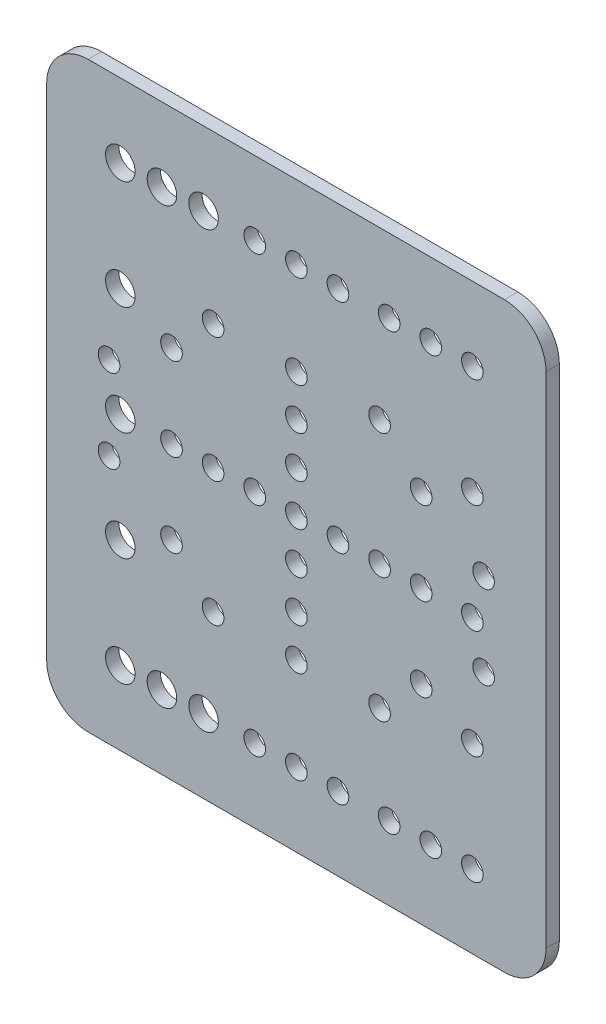
from build123d import *

# Parameters (mm, degrees)
SKETCH1_W           = 120
SKETCH1_H           = 140
SKETCH1_R           = 2.6
SKETCH1_R_2         = 3.55
BOSS_EXTRUDE1_DEPTH = 3.2
FILLET1_R           = 10


with BuildPart() as part:
    # Sketch1 → Boss-Extrude1 (new body)
    with BuildSketch(Plane.XY):
        Rectangle(SKETCH1_W, SKETCH1_H)
        Circle(SKETCH1_R, mode=Mode.SUBTRACT)
        with Locations((10, 0)):
            Circle(SKETCH1_R, mode=Mode.SUBTRACT)
        with Locations((20, 0)):
            Circle(SKETCH1_R, mode=Mode.SUBTRACT)
        with Locations((30, 0)):
            Circle(SKETCH1_R, mode=Mode.SUBTRACT)
        with Locations((-10, 0)):
            Circle(SKETCH1_R, mode=Mode.SUBTRACT)
        with Locations((-20, 0)):
            Circle(SKETCH1_R, mode=Mode.SUBTRACT)
        with Locations((-30, 0)):
            Circle(SKETCH1_R, mode=Mode.SUBTRACT)
        with Locations((0, 10)):
            Circle(SKETCH1_R, mode=Mode.SUBTRACT)
        with Locations((0, 20)):
            Circle(SKETCH1_R, mode=Mode.SUBTRACT)
        with Locations((0, 30)):
            Circle(SKETCH1_R, mode=Mode.SUBTRACT)
        with Locations((0, -10)):
            Circle(SKETCH1_R, mode=Mode.SUBTRACT)
        with Locations((0, -20)):
            Circle(SKETCH1_R, mode=Mode.SUBTRACT)
        with Locations((0, -30)):
            Circle(SKETCH1_R, mode=Mode.SUBTRACT)
        with Locations((42.3, 0)):
            Circle(SKETCH1_R, mode=Mode.SUBTRACT)
        with Locations((-42.3, 0)):
            Circle(SKETCH1_R_2, mode=Mode.SUBTRACT)
        with Locations((-42.3, 26.15)):
            Circle(SKETCH1_R_2, mode=Mode.SUBTRACT)
        with Locations((-42.3, 52.3)):
            Circle(SKETCH1_R_2, mode=Mode.SUBTRACT)
        with Locations((-42.3, -26.15)):
            Circle(SKETCH1_R_2, mode=Mode.SUBTRACT)
        with Locations((-42.3, -52.3)):
            Circle(SKETCH1_R_2, mode=Mode.SUBTRACT)
        with Locations((42.3, 26.15)):
            Circle(SKETCH1_R, mode=Mode.SUBTRACT)
        with Locations((42.3, 52.3)):
            Circle(SKETCH1_R, mode=Mode.SUBTRACT)
        with Locations((42.3, -26.15)):
            Circle(SKETCH1_R, mode=Mode.SUBTRACT)
        with Locations((42.3, -52.3)):
            Circle(SKETCH1_R, mode=Mode.SUBTRACT)
        with Locations((-32.3, 52.3)):
            Circle(SKETCH1_R_2, mode=Mode.SUBTRACT)
        with Locations((-22.3, 52.3)):
            Circle(SKETCH1_R_2, mode=Mode.SUBTRACT)
        with Locations((-32.3, -52.3)):
            Circle(SKETCH1_R_2, mode=Mode.SUBTRACT)
        with Locations((-22.3, -52.3)):
            Circle(SKETCH1_R_2, mode=Mode.SUBTRACT)
        with Locations((32.3, 52.3)):
            Circle(SKETCH1_R, mode=Mode.SUBTRACT)
        with Locations((22.3, 52.3)):
            Circle(SKETCH1_R, mode=Mode.SUBTRACT)
        with Locations((32.3, -52.3)):
            Circle(SKETCH1_R, mode=Mode.SUBTRACT)
        with Locations((22.3, -52.3)):
            Circle(SKETCH1_R, mode=Mode.SUBTRACT)
        with Locations((0, 52.3)):
            Circle(SKETCH1_R, mode=Mode.SUBTRACT)
        with Locations((10, 52.3)):
            Circle(SKETCH1_R, mode=Mode.SUBTRACT)
        with Locations((-10, 52.3)):
            Circle(SKETCH1_R, mode=Mode.SUBTRACT)
        with Locations((-20, 30)):
            Circle(SKETCH1_R, mode=Mode.SUBTRACT)
        with Locations((20, 30)):
            Circle(SKETCH1_R, mode=Mode.SUBTRACT)
        with Locations((-30, 20)):
            Circle(SKETCH1_R, mode=Mode.SUBTRACT)
        with Locations((30, 20)):
            Circle(SKETCH1_R, mode=Mode.SUBTRACT)
        with Locations((-45, 10)):
            Circle(SKETCH1_R, mode=Mode.SUBTRACT)
        with Locations((45, 10)):
            Circle(SKETCH1_R, mode=Mode.SUBTRACT)
        with Locations((45, -10)):
            Circle(SKETCH1_R, mode=Mode.SUBTRACT)
        with Locations((30, -20)):
            Circle(SKETCH1_R, mode=Mode.SUBTRACT)
        with Locations((20, -30)):
            Circle(SKETCH1_R, mode=Mode.SUBTRACT)
        with Locations((10, -52.3)):
            Circle(SKETCH1_R, mode=Mode.SUBTRACT)
        with Locations((0, -52.3)):
            Circle(SKETCH1_R, mode=Mode.SUBTRACT)
        with Locations((-10, -52.3)):
            Circle(SKETCH1_R, mode=Mode.SUBTRACT)
        with Locations((-20, -30)):
            Circle(SKETCH1_R, mode=Mode.SUBTRACT)
        with Locations((-30, -20)):
            Circle(SKETCH1_R, mode=Mode.SUBTRACT)
        with Locations((-45, -10)):
            Circle(SKETCH1_R, mode=Mode.SUBTRACT)
    extrude(amount=-BOSS_EXTRUDE1_DEPTH)

    # Fillet1
    fillet1_edges = [part.edges().sort_by_distance(p)[0] for p in [
        (60, -70, -1.6),
        (-60, -70, -1.6),
        (-60, 70, -1.6),
        (60, 70, -1.6),
    ]]
    fillet(fillet1_edges, radius=FILLET1_R)


solid = part.part
